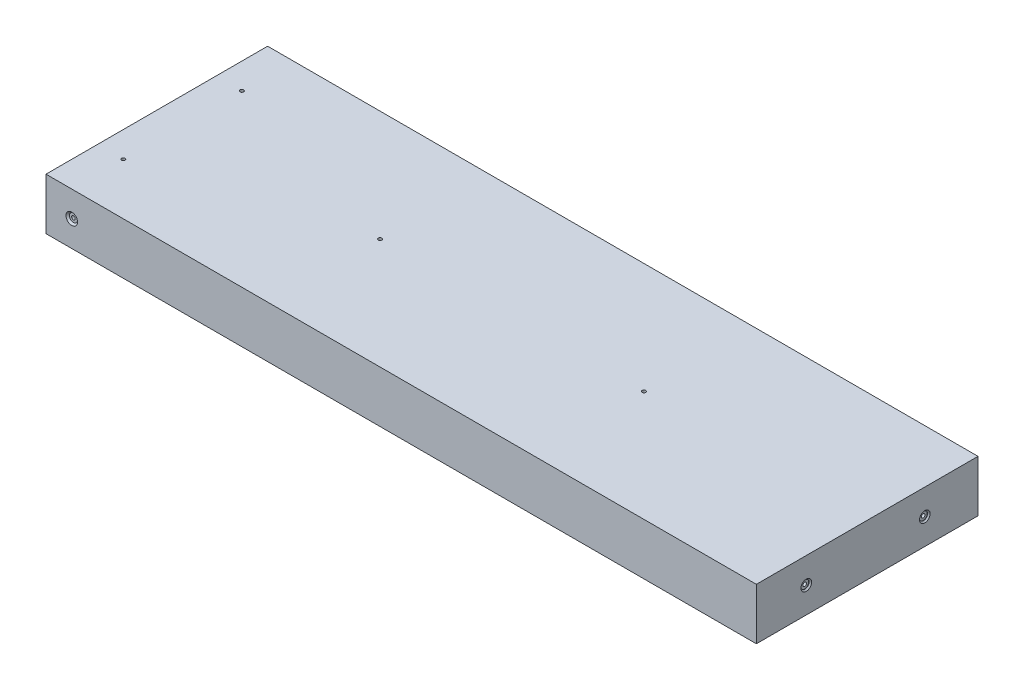
from build123d import *

# Parameters (mm, degrees)
SKETCH1_W                                   = 350
SKETCH1_H                                   = 109.2
BOSS_EXTRUDE1_DEPTH                         = 25.4
CBORE_FOR_0_BINDING_HEAD_MACHINE_SC_2_COUNT = 2
CBORE_FOR_0_BINDING_HEAD_MACHINE_SC_2_PITCH = 58.4
CBORE_FOR_0_BINDING_HEAD_MACHINE_SC_3_COUNT = 2
CBORE_FOR_0_BINDING_HEAD_MACHINE_SC_3_PITCH = 130
CBORE_FOR_0_BINDING_HEAD_MACHINE_SC_4_COUNT = 2
CBORE_FOR_0_BINDING_HEAD_MACHINE_SC_4_PITCH = 58.4


with BuildPart() as part:
    # Sketch1 → Boss-Extrude1 (new body)
    with BuildSketch(Plane(origin=(0, 0, 0), x_dir=(1, 0, 0), z_dir=(0, 1, 0))):
        Rectangle(SKETCH1_W, SKETCH1_H)
    extrude(amount=BOSS_EXTRUDE1_DEPTH)

    # Sketch3 → CBORE for #0 Binding Head Machine Screw1 (revolve, cut)
    with BuildSketch(Plane(origin=(-162.3, 12.7, 54.6), x_dir=(0, -1, 0), z_dir=(1, 0, 0))):
        Polygon((0, 0), (0, 30.53416509), (0.889, 30), (0.889, 0.8128), (1.98501, 0.8128), (1.98501, 0.87249), (2.8575, 0), align=None)
    cbore_for_0_binding_head_machine_screw1 = revolve(axis=Axis((-162.3, 12.7, 60.95), (0, 0, -1)), mode=Mode.SUBTRACT)

    # Mirror1: CBORE for #0 Binding Head Machine Screw1 across plane
    add(cbore_for_0_binding_head_machine_screw1.mirror(Plane.XY), mode=Mode.SUBTRACT)

    # Sketch5 → CBORE for #0 Binding Head Machine Screw2 (revolve, cut)
    with BuildSketch(Plane(origin=(175, 12.7, 30), x_dir=(0, 0, -1), z_dir=(0, 1, 0))):
        Polygon((0, 0), (0, 30.53416509), (0.889, 30), (0.889, 0.8128), (1.98501, 0.8128), (1.98501, 0.635), (2.62001, 0), align=None)
    cbore_for_0_binding_head_machine_screw2 = revolve(axis=Axis((181.35, 12.7, 30), (-1, 0, 0)), mode=Mode.SUBTRACT)

    # CBORE for _0 Binding Head Machine Sc 2: CBORE for #0 Binding Head Machine Screw2 ×2
    with Locations(*[(0, 0, -i * CBORE_FOR_0_BINDING_HEAD_MACHINE_SC_2_PITCH) for i in range(1, CBORE_FOR_0_BINDING_HEAD_MACHINE_SC_2_COUNT)]):
        add(cbore_for_0_binding_head_machine_screw2, mode=Mode.SUBTRACT)

    # Sketch9 → CBORE for #0 Binding Head Machine Screw4 (revolve, cut)
    with BuildSketch(Plane(origin=(-65, 0, 0), x_dir=(0, 0, -1), z_dir=(1, 0, 0))):
        Polygon((0, 0), (0, 30.53416509), (0.889, 30), (0.889, 0.8128), (1.98501, 0.8128), (1.98501, 0.87249), (2.8575, 0), align=None)
    cbore_for_0_binding_head_machine_screw4 = revolve(axis=Axis((-65, -6.35, 0), (0, 1, 0)), mode=Mode.SUBTRACT)

    # CBORE for _0 Binding Head Machine Sc 3: CBORE for #0 Binding Head Machine Screw4 ×2
    with Locations(*[(i * CBORE_FOR_0_BINDING_HEAD_MACHINE_SC_3_PITCH, 0, 0) for i in range(1, CBORE_FOR_0_BINDING_HEAD_MACHINE_SC_3_COUNT)]):
        add(cbore_for_0_binding_head_machine_screw4, mode=Mode.SUBTRACT)

    # Sketch13 → CBORE for #0 Binding Head Machine Screw6 (revolve, cut)
    with BuildSketch(Plane(origin=(-162.3, 0, -29.2), x_dir=(0, 0, -1), z_dir=(1, 0, 0))):
        Polygon((0, 0), (0, 25.4), (0.889, 25.4), (0.889, 0.8128), (1.98501, 0.8128), (1.98501, 0.87249), (2.8575, 0), align=None)
    cbore_for_0_binding_head_machine_screw6 = revolve(axis=Axis((-162.3, -6.35, -29.2), (0, 1, 0)), mode=Mode.SUBTRACT)

    # CBORE for _0 Binding Head Machine Sc 4: CBORE for #0 Binding Head Machine Screw6 ×2
    with Locations(*[(0, 0, i * CBORE_FOR_0_BINDING_HEAD_MACHINE_SC_4_PITCH) for i in range(1, CBORE_FOR_0_BINDING_HEAD_MACHINE_SC_4_COUNT)]):
        add(cbore_for_0_binding_head_machine_screw6, mode=Mode.SUBTRACT)


solid = part.part
